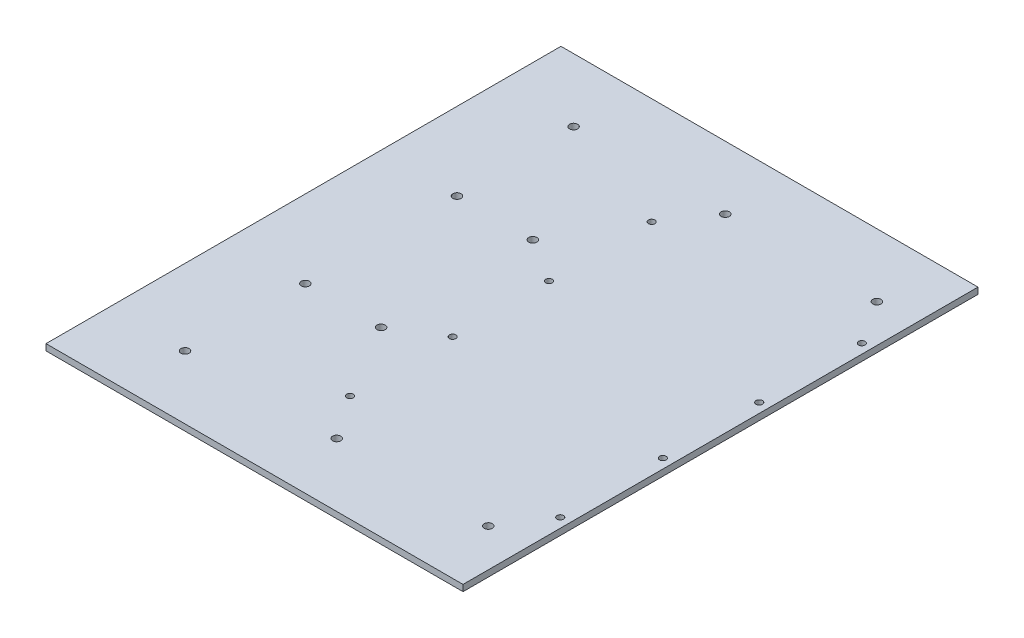
from build123d import *

# Parameters (mm, degrees)
SKETCH1_W                    = 419.1
SKETCH1_H                    = 517.525
BOSS_EXTRUDE1_DEPTH          = 6.35
F_0_257_DIAMETER_HOLE1_D     = 6.5278
F_0_257_DIAMETER_HOLE1_DEPTH = 6.35
P_0_323_DIAMETER_HOLE1_D     = 8.2042
CUT_EXTRUDE2_REACH           = 8.35
SKETCH9_R                    = 4.1021


with BuildPart() as part:
    # Sketch1 → Boss-Extrude1 (new body)
    with BuildSketch(Plane(origin=(0, 0, 0), x_dir=(1, 0, 0), z_dir=(0, 1, 0))):
        with Locations((93.382352941, 0)):
            Rectangle(SKETCH1_W, SKETCH1_H)
    extrude(amount=-BOSS_EXTRUDE1_DEPTH)

    # F (0.257) Diameter Hole1
    with Locations(Plane(origin=(0, 0, 0), x_dir=(1, 0, 0), z_dir=(0, 1, 0))):
        with Locations((82.142852941, -151.562), (293.407352941, -151.562), (82.142852941, -48.438), (293.407352941, -48.438), (293.407352941, 48.438), (82.142852941, 48.438), (82.142852941, 151.562), (293.407352941, 151.562)):
            Hole(F_0_257_DIAMETER_HOLE1_D / 2, depth=F_0_257_DIAMETER_HOLE1_DEPTH)

    # P (0.323) Diameter Hole1 (through all)
    with Locations(Plane(origin=(0, 0, 0), x_dir=(1, 0, 0), z_dir=(0, 1, 0))):
        with Locations((-38.1, -76.2), (38.1, -76.2), (38.1, 76.2), (-38.1, 76.2)):
            Hole(P_0_323_DIAMETER_HOLE1_D / 2)

    # Sketch9 → Cut-Extrude2 (cut, up to next)
    with BuildSketch(Plane(origin=(0, 0, 0), x_dir=(1, 0, 0), z_dir=(0, 1, 0)), mode=Mode.PRIVATE) as cut_extrude2_sk1:
        with Locations((264.832352941, -195.2625)):
            Circle(SKETCH9_R)
    cut_extrude2_tool1 = extrude(cut_extrude2_sk1.sketch, amount=-CUT_EXTRUDE2_REACH, mode=Mode.PRIVATE) & part.part
    add(cut_extrude2_tool1.solids().sort_by_distance((264.832353, 0, 195.2625))[0], mode=Mode.SUBTRACT)
    # Sketch9 → Cut-Extrude2 (cut, up to next)
    with BuildSketch(Plane(origin=(0, 0, 0), x_dir=(1, 0, 0), z_dir=(0, 1, 0)), mode=Mode.PRIVATE) as cut_extrude2_sk2:
        with Locations((112.432352941, -195.2625)):
            Circle(SKETCH9_R)
    cut_extrude2_tool2 = extrude(cut_extrude2_sk2.sketch, amount=-CUT_EXTRUDE2_REACH, mode=Mode.PRIVATE) & part.part
    add(cut_extrude2_tool2.solids().sort_by_distance((112.432353, 0, 195.2625))[0], mode=Mode.SUBTRACT)
    # Sketch9 → Cut-Extrude2 (cut, up to next)
    with BuildSketch(Plane(origin=(0, 0, 0), x_dir=(1, 0, 0), z_dir=(0, 1, 0)), mode=Mode.PRIVATE) as cut_extrude2_sk3:
        with Locations((-39.967647059, -195.2625)):
            Circle(SKETCH9_R)
    cut_extrude2_tool3 = extrude(cut_extrude2_sk3.sketch, amount=-CUT_EXTRUDE2_REACH, mode=Mode.PRIVATE) & part.part
    add(cut_extrude2_tool3.solids().sort_by_distance((-39.967647, 0, 195.2625))[0], mode=Mode.SUBTRACT)
    # Sketch9 → Cut-Extrude2 (cut, up to next)
    with BuildSketch(Plane(origin=(0, 0, 0), x_dir=(1, 0, 0), z_dir=(0, 1, 0)), mode=Mode.PRIVATE) as cut_extrude2_sk4:
        with Locations((112.432352941, 195.2625)):
            Circle(SKETCH9_R)
    cut_extrude2_tool4 = extrude(cut_extrude2_sk4.sketch, amount=-CUT_EXTRUDE2_REACH, mode=Mode.PRIVATE) & part.part
    add(cut_extrude2_tool4.solids().sort_by_distance((112.432353, 0, -195.2625))[0], mode=Mode.SUBTRACT)
    # Sketch9 → Cut-Extrude2 (cut, up to next)
    with BuildSketch(Plane(origin=(0, 0, 0), x_dir=(1, 0, 0), z_dir=(0, 1, 0)), mode=Mode.PRIVATE) as cut_extrude2_sk5:
        with Locations((-39.967647059, 195.2625)):
            Circle(SKETCH9_R)
    cut_extrude2_tool5 = extrude(cut_extrude2_sk5.sketch, amount=-CUT_EXTRUDE2_REACH, mode=Mode.PRIVATE) & part.part
    add(cut_extrude2_tool5.solids().sort_by_distance((-39.967647, 0, -195.2625))[0], mode=Mode.SUBTRACT)
    # Sketch9 → Cut-Extrude2 (cut, up to next)
    with BuildSketch(Plane(origin=(0, 0, 0), x_dir=(1, 0, 0), z_dir=(0, 1, 0)), mode=Mode.PRIVATE) as cut_extrude2_sk6:
        with Locations((264.832352941, 195.2625)):
            Circle(SKETCH9_R)
    cut_extrude2_tool6 = extrude(cut_extrude2_sk6.sketch, amount=-CUT_EXTRUDE2_REACH, mode=Mode.PRIVATE) & part.part
    add(cut_extrude2_tool6.solids().sort_by_distance((264.832353, 0, -195.2625))[0], mode=Mode.SUBTRACT)


solid = part.part
